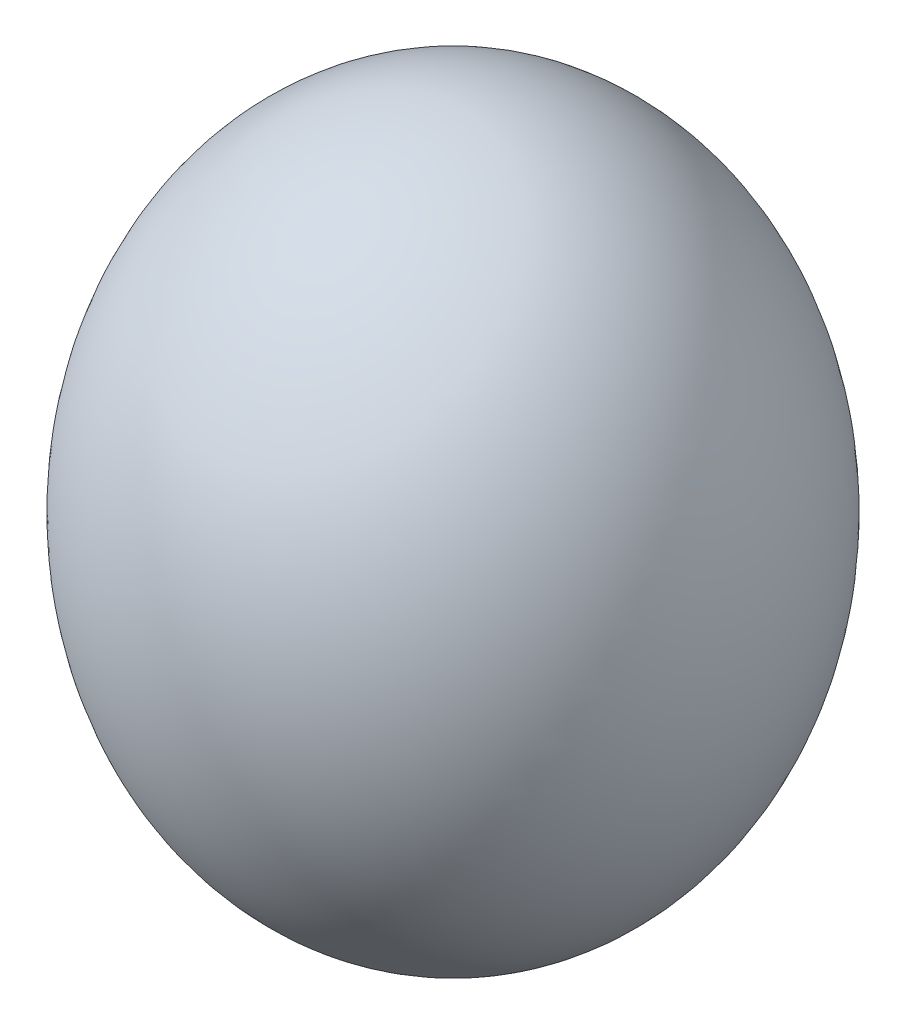
from build123d import *


with BuildPart() as part:
    # Croquis1 → Revolución1 (revolve)
    with BuildSketch(Plane.XY):
        with BuildLine():
            Line((0, 0), (0, 65.6))
            add(Edge.make_bspline(
                [(0, 0), (27, 0), (27, 32.8), (27, 65.6), (0, 65.6)],
                knots=[3.141592654, 3.141592654, 3.141592654, 4.71238898, 4.71238898, 6.283185307, 6.283185307, 6.283185307], degree=2, weights=[1, 0.707106781, 1, 0.707106781, 1]))
        make_face()
    revolve(axis=Axis((0, 0, 0), (0, 1, 0)))


solid = part.part
